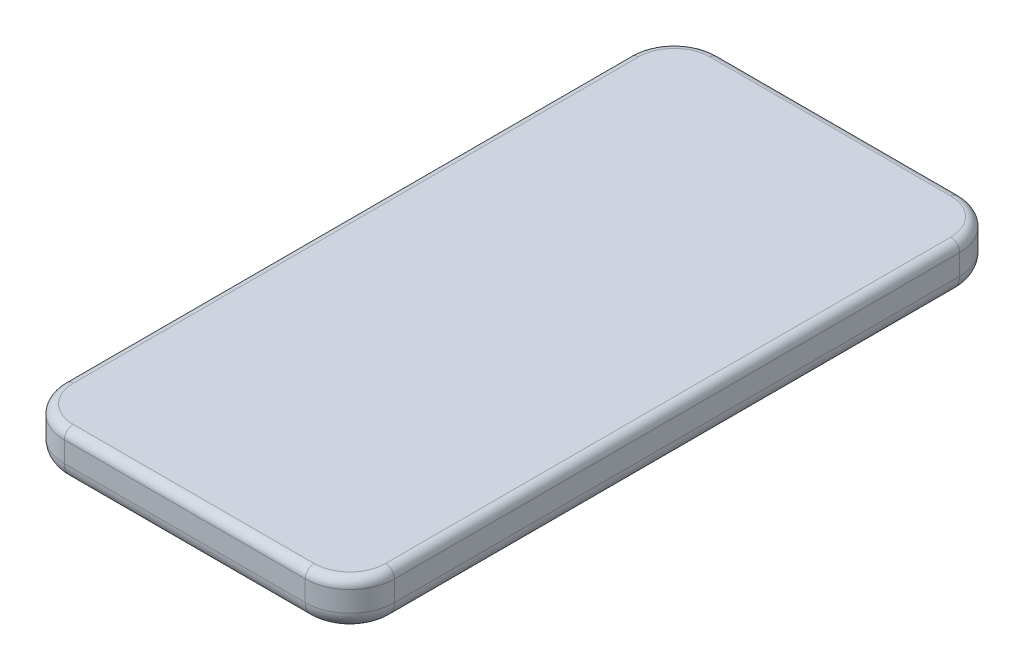
from build123d import *

# Parameters (mm, degrees)
SKETCH_1_W      = 74
SKETCH_1_H      = 146.7
EXTRUDE_1_DEPTH = 10.6
FILLET_1_R      = 10
FILLET_2_R      = 4
FILLET_3_R      = 2


with BuildPart() as part:
    # 草图1 → 凸台-拉伸1 (new body)
    with BuildSketch(Plane(origin=(0, 0, 0), x_dir=(1, 0, 0), z_dir=(0, 1, 0))):
        with Locations((0, -73.35)):
            Rectangle(SKETCH_1_W, SKETCH_1_H)
    extrude(amount=EXTRUDE_1_DEPTH)

    # 圆角1
    fillet_1_edges = [part.edges().sort_by_distance(p)[0] for p in [
        (-37, 5.3, 0),
        (37, 5.3, 0),
        (37, 5.3, 146.7),
        (-37, 5.3, 146.7),
    ]]
    fillet(fillet_1_edges, radius=FILLET_1_R)

    # 圆角2
    fillet_2_edges = [part.edges().sort_by_distance(p)[0] for p in [
        (37, 0, 73.35),
        (-37, 0, 73.35),
        (0, 0, 0),
        (0, 0, 146.7),
        (34.071067812, 0, 2.928932188),
        (-34.071067812, 0, 2.928932188),
        (-34.071067812, 0, 143.771067812),
        (34.071067812, 0, 143.771067812),
    ]]
    fillet(fillet_2_edges, radius=FILLET_2_R)

    # 圆角3
    fillet_3_edges = [part.edges().sort_by_distance(p)[0] for p in [
        (37, 10.6, 73.35),
        (0, 10.6, 146.7),
        (-37, 10.6, 73.35),
        (0, 10.6, 0),
        (34.071067812, 10.6, 2.928932188),
        (-34.071067812, 10.6, 2.928932188),
        (-34.071067812, 10.6, 143.771067812),
        (34.071067812, 10.6, 143.771067812),
    ]]
    fillet(fillet_3_edges, radius=FILLET_3_R)


solid = part.part
